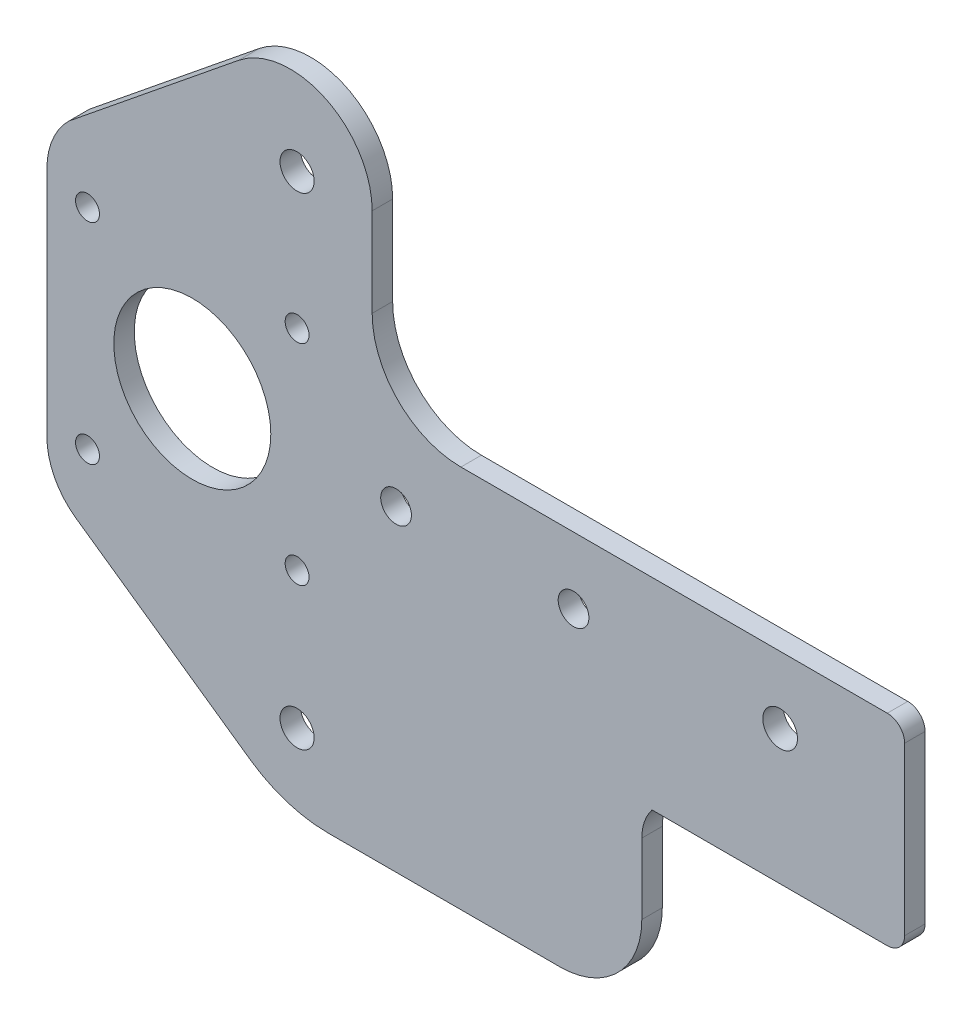
from build123d import *

# Parameters (mm, degrees)
SKETCH1_R           = 2.54
SKETCH1_R_2         = 2.25
SKETCH1_R_3         = 1.75
SKETCH1_R_4         = 2.5
SKETCH1_R_5         = 11.5
BOSS_EXTRUDE1_DEPTH = 3
FILLET2_R           = 2.54


with BuildPart() as part:
    # Sketch1 → Boss-Extrude1 (new body)
    with BuildSketch(Plane.XY):
        with BuildLine():
            Line((0, 0), (0, -29.5))
            Line((0, -29.5), (-37, -29.5))
            ThreePointArc((-37, -29.5), (-38.114378278, -31.538839171), (-38.5, -33.830127019))
            Line((-38.5, -33.830127019), (-38.5, -44.16209895))
            ThreePointArc((-38.5, -44.16209895), (-42.014718626, -52.647380324), (-50.5, -56.16209895))
            Line((-50.5, -56.16209895), (-84.414235636, -56.16209895))
            ThreePointArc((-84.414235636, -56.16209895), (-90.428351627, -55.236437965), (-95.885764364, -52.545139836))
            Line((-95.885764364, -52.545139836), (-121.385764364, -34.689847611))
            ThreePointArc((-121.385764364, -34.689847611), (-124.520108332, -31.115813301), (-125.65, -26.498327168))
            Line((-125.65, -26.498327168), (-125.65, 7.501672832))
            ThreePointArc((-125.65, 7.501672832), (-124.809828805, 11.670050653), (-122.420515459, 15.187499024))
            Line((-122.420515459, 15.187499024), (-97.551844693, 35.325751537))
            ThreePointArc((-97.551844693, 35.325751537), (-84.833866838, 36.831023412), (-78, 26))
            Line((-78, 26), (-78, 13))
            ThreePointArc((-78, 13), (-74.192388155, 3.807611845), (-65, 0))
            Line((-65, 0), (0, 0))
        make_face()
        with Locations((-18.237, -9.806)):
            Circle(SKETCH1_R, mode=Mode.SUBTRACT)
        with Locations((-48.5, -9.75)):
            Circle(SKETCH1_R_2, mode=Mode.SUBTRACT)
        with Locations((-74.5, -9.75)):
            Circle(SKETCH1_R_2, mode=Mode.SUBTRACT)
        with Locations((-89, 5.6)):
            Circle(SKETCH1_R_3, mode=Mode.SUBTRACT)
        with Locations((-89, 25.5)):
            Circle(SKETCH1_R_4, mode=Mode.SUBTRACT)
        with Locations((-89, -25.1)):
            Circle(SKETCH1_R_3, mode=Mode.SUBTRACT)
        with Locations((-89, -45.112)):
            Circle(SKETCH1_R_4, mode=Mode.SUBTRACT)
        with Locations((-104.35, -9.75)):
            Circle(SKETCH1_R_5, mode=Mode.SUBTRACT)
        with Locations((-119.7, 5.6)):
            Circle(SKETCH1_R_3, mode=Mode.SUBTRACT)
        with Locations((-119.7, -25.1)):
            Circle(SKETCH1_R_3, mode=Mode.SUBTRACT)
    extrude(amount=BOSS_EXTRUDE1_DEPTH)

    # Fillet2
    fillet2_edges = [part.edges().sort_by_distance(p)[0] for p in [
        (0, 0, 1.5),
        (0, -29.5, 1.5),
    ]]
    fillet(fillet2_edges, radius=FILLET2_R)


solid = part.part
